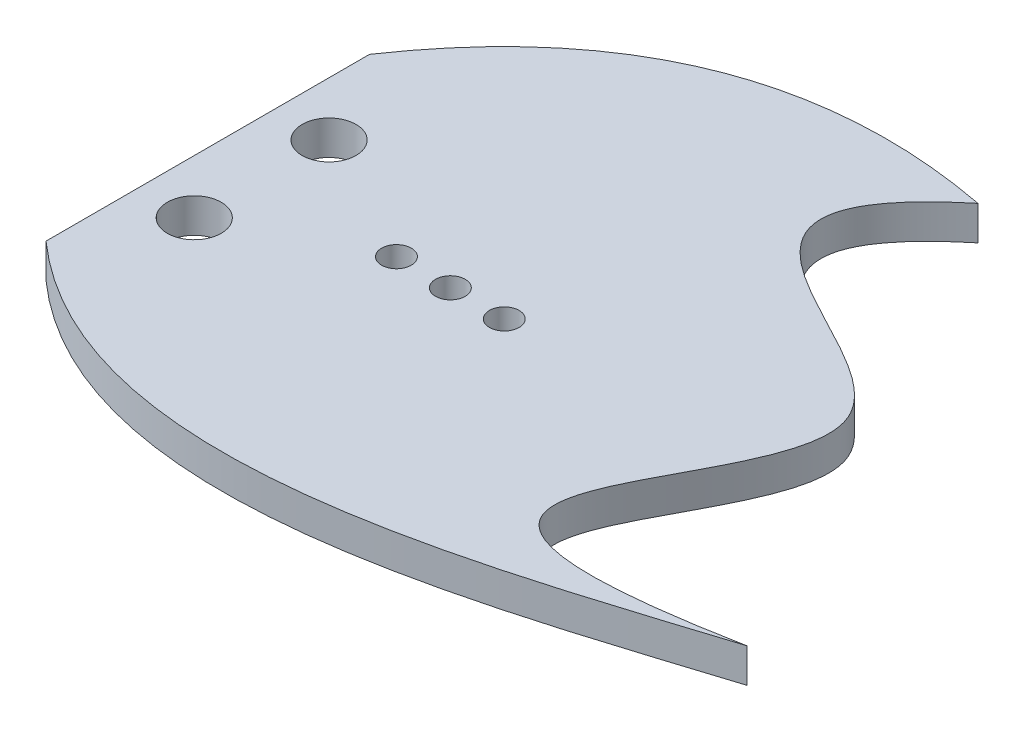
from build123d import *

# Parameters (mm, degrees)
BOSS_EXTRUDE1_DEPTH = 6.35
SKETCH3_R           = 2.75
CUT_EXTRUDE1_DEPTH  = 6.35
SKETCH4_R           = 5
CUT_EXTRUDE2_DEPTH  = 6.35
SKETCH5_R           = 2.75
CUT_EXTRUDE3_DEPTH  = 6.35


with BuildPart() as part:
    # Sketch2 → Boss-Extrude1 (new body)
    with BuildSketch(Plane(origin=(0, 0, 0), x_dir=(1, 0, 0), z_dir=(0, 1, 0))):
        with BuildLine():
            Line((56.391825432, 108.15139225), (56.391825432, 48.15139225))
            add(Edge.make_bspline(
                [(56.391825432, 48.15139225), (92.653221865, 15.965688803), (146.224111167, 35.551280798), (186.391825432, 48.15139225)],
                knots=[0, 0, 0, 0, 1, 1, 1, 1], degree=3))
            add(Edge.make_bspline(
                [(186.391825432, 48.15139225), (110.317005066, 33.459687001), (213.908429008, 108.517638804), (101.791603924, 111.907716317), (136.76058899, 140.645969256)],
                knots=[0, 0, 0, 0, 0.539021374, 1, 1, 1, 1], degree=3))
            add(Edge.make_bspline(
                [(56.391825432, 108.15139225), (85.056395763, 150.553247728), (136.76058899, 140.645969256)],
                knots=[0, 0, 0, 1, 1, 1], degree=2))
        make_face()
    extrude(amount=BOSS_EXTRUDE1_DEPTH)

    # Sketch3 → Cut-Extrude1 (cut)
    with BuildSketch(Plane(origin=(0, 0, 0), x_dir=(1, 0, 0), z_dir=(0, 1, 0))):
        with Locations((101.391825432, 78.15139225)):
            Circle(SKETCH3_R)
    extrude(amount=CUT_EXTRUDE1_DEPTH, mode=Mode.SUBTRACT)

    # Sketch4 → Cut-Extrude2 (cut)
    with BuildSketch(Plane(origin=(0, 0, 0), x_dir=(1, 0, 0), z_dir=(0, 1, 0))):
        with Locations((66.391825432, 90.65139225)):
            Circle(SKETCH4_R)
        with Locations((66.391825432, 65.65139225)):
            Circle(SKETCH4_R)
    extrude(amount=CUT_EXTRUDE2_DEPTH, mode=Mode.SUBTRACT)

    # Sketch5 → Cut-Extrude3 (cut)
    with BuildSketch(Plane(origin=(0, 0, 0), x_dir=(1, 0, 0), z_dir=(0, 1, 0))):
        with Locations((101.391825432, 78.15139225)):
            Circle(SKETCH5_R)
        with Locations((111.391825432, 78.15139225)):
            Circle(SKETCH5_R)
        with Locations((91.391825432, 78.15139225)):
            Circle(SKETCH5_R)
    extrude(amount=CUT_EXTRUDE3_DEPTH, mode=Mode.SUBTRACT)


solid = part.part
